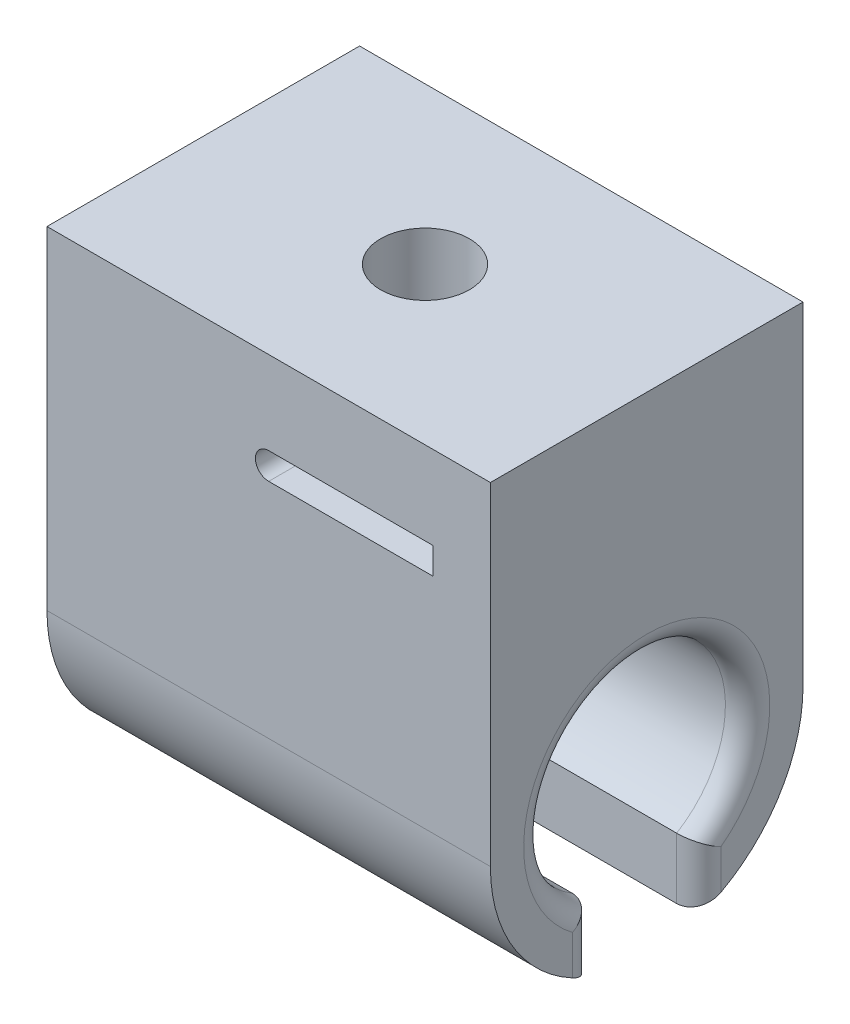
from build123d import *

# Parameters (mm, degrees)
SKETCH1_R           = 5.7785
BOSS_EXTRUDE1_DEPTH = 25.4
CUT_EXTRUDE1_REACH  = 40.853
SKETCH2_R           = 2.54
SKETCH3_W           = 5.969
SKETCH3_H           = 4.005387026
CUT_EXTRUDE2_DEPTH  = 33.988295999
FILLET1_R           = 1.27
CUT_EXTRUDE4_DEPTH  = 31.887708266


with BuildPart() as part:
    # Sketch1 → Boss-Extrude1 (new body)
    with BuildSketch(Plane(origin=(0, 0, 0), x_dir=(0, 0, -1), z_dir=(1, 0, 0))):
        with BuildLine():
            Line((-8.9535, 19.05), (-8.9535, 0))
            ThreePointArc((-8.9535, 0), (0, -8.9535), (8.9535, 0))
            Line((8.9535, 0), (8.9535, 19.05))
            Line((8.9535, 19.05), (-8.9535, 19.05))
        make_face()
        Circle(SKETCH1_R, mode=Mode.SUBTRACT)
    extrude(amount=BOSS_EXTRUDE1_DEPTH)

    # Sketch2 → Cut-Extrude1 (cut, up to next)
    with BuildSketch(Plane(origin=(0, 19.05, 0), x_dir=(1, 0, 0), z_dir=(0, 1, 0)), mode=Mode.PRIVATE) as cut_extrude1_sk1:
        with Locations(Location((12.7, 0, 0), (0, 0, 270))):
            Circle(SKETCH2_R)
    cut_extrude1_tool1 = extrude(cut_extrude1_sk1.sketch, amount=-CUT_EXTRUDE1_REACH, mode=Mode.PRIVATE) & part.part
    add(cut_extrude1_tool1.solids().sort_by_distance((12.7, 19.05, 0))[0], mode=Mode.SUBTRACT)
    add(cut_extrude1_tool1.solids().sort_by_distance((12.7, 19.05, 0))[1], mode=Mode.SUBTRACT)

    # Sketch3 → Cut-Extrude2 (cut, through all)
    with BuildSketch(Plane.ZY):
        with Locations((0, -6.950806487)):
            Rectangle(SKETCH3_W, SKETCH3_H)
    extrude(amount=-CUT_EXTRUDE2_DEPTH, mode=Mode.SUBTRACT)

    # Fillet1
    fillet1_edges = [part.edges().sort_by_distance(p)[0] for p in [
        (0, 5.031748975, 2.84122588),
        (0, -6.694776864, 2.9845),
        (25.4, 5.031748975, 2.84122588),
        (0, -6.694776864, -2.9845),
        (25.4, -6.694776864, -2.9845),
        (25.4, -6.694776864, 2.9845),
    ]]
    fillet(fillet1_edges, radius=FILLET1_R)

    # Sketch6 → Cut-Extrude4 (cut, through all)
    with BuildSketch(Plane(origin=(16.4465, 0, -8.9535), x_dir=(1, 0, 0), z_dir=(0, 0, 1))):
        with BuildLine():
            Line((5.6515, 14.282208418), (-3.7465, 14.282208418))
            ThreePointArc((-3.7465, 14.282208418), (-4.5085, 13.520208418), (-3.7465, 12.758208418))
            Line((-3.7465, 12.758208418), (5.6515, 12.758208418))
            Line((5.6515, 12.758208418), (5.6515, 14.282208418))
        make_face()
    extrude(amount=CUT_EXTRUDE4_DEPTH, mode=Mode.SUBTRACT)


solid = part.part
